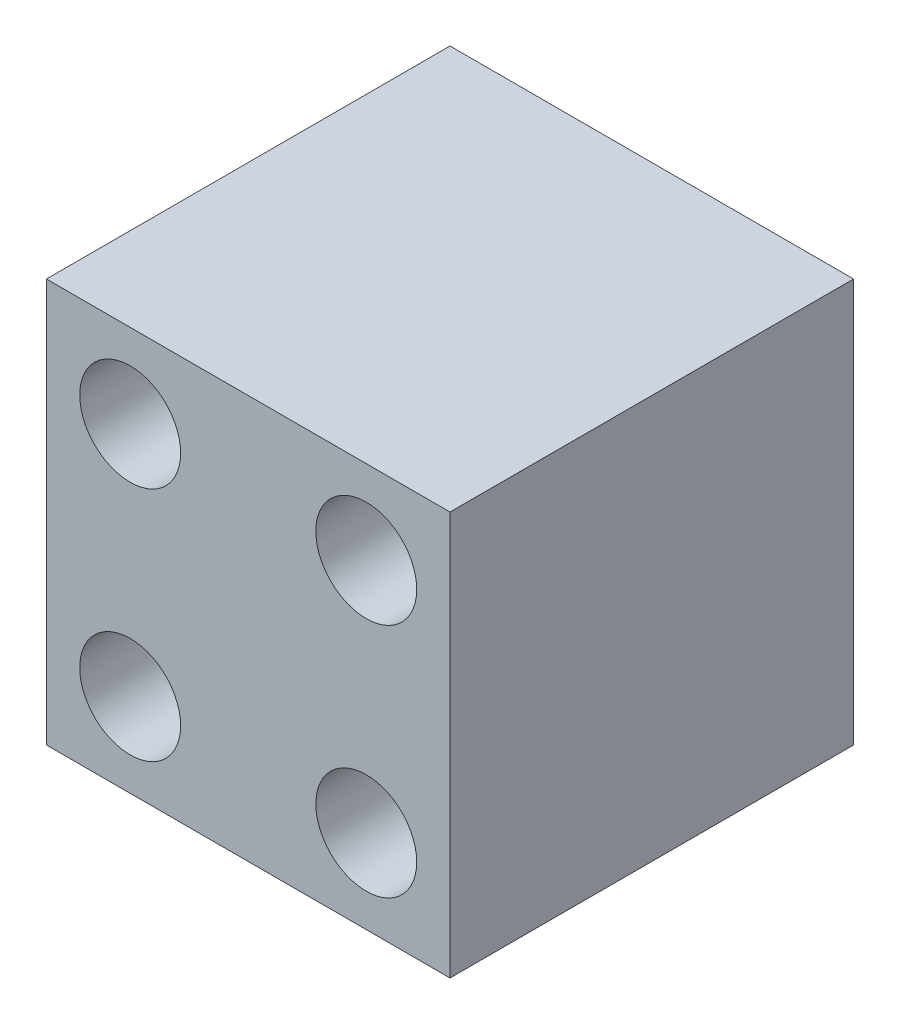
from build123d import *

# Parameters (mm, degrees)
SKETCH1_W           = 40
SKETCH1_H           = 40
SKETCH1_R           = 5
BOSS_EXTRUDE1_DEPTH = 40


with BuildPart() as part:
    # Sketch1 → Boss-Extrude1 (new body)
    with BuildSketch(Plane.XY):
        with Locations((20, 20)):
            Rectangle(SKETCH1_W, SKETCH1_H)
        with Locations((8.3, 31.7)):
            Circle(SKETCH1_R, mode=Mode.SUBTRACT)
        with Locations((31.7, 31.7)):
            Circle(SKETCH1_R, mode=Mode.SUBTRACT)
        with Locations((8.3, 8.3)):
            Circle(SKETCH1_R, mode=Mode.SUBTRACT)
        with Locations((31.7, 8.3)):
            Circle(SKETCH1_R, mode=Mode.SUBTRACT)
    extrude(amount=BOSS_EXTRUDE1_DEPTH)


solid = part.part
